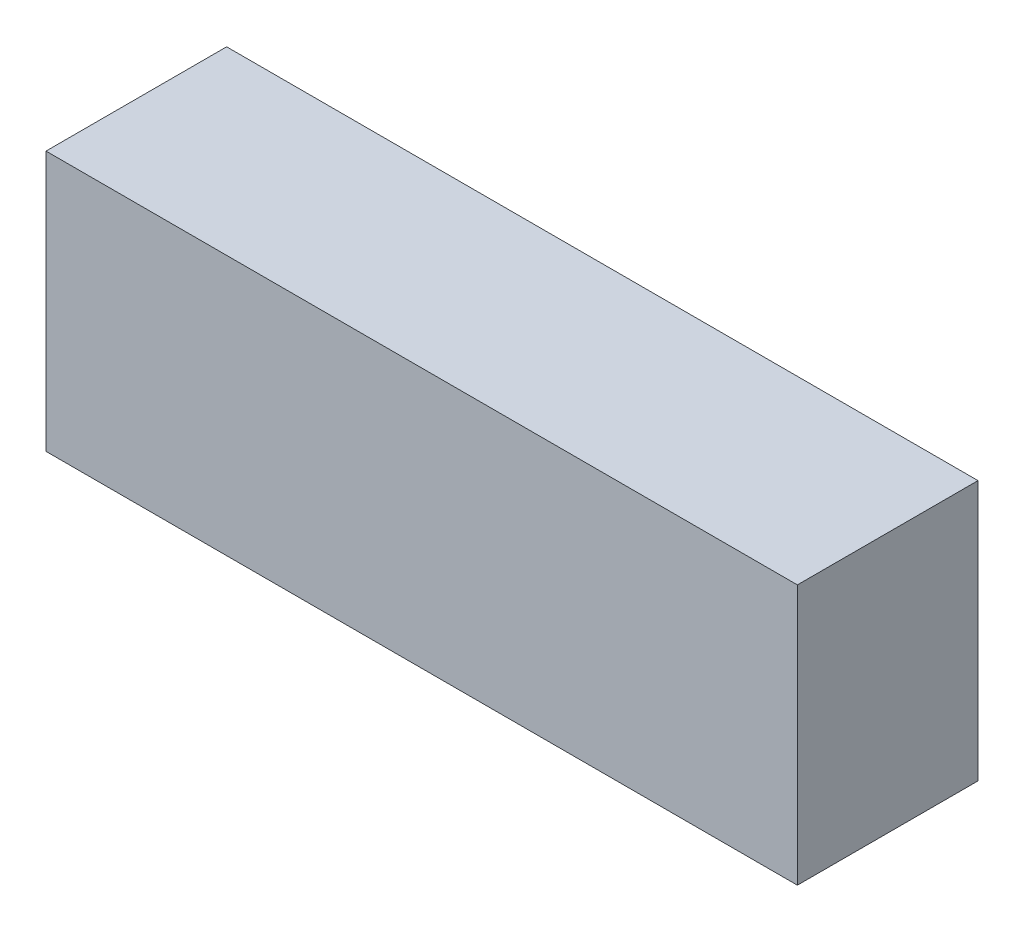
from build123d import *

# Parameters (mm, degrees)
SKETCH1_W           = 104
SKETCH1_H           = 36
BOSS_EXTRUDE1_DEPTH = 25


with BuildPart() as part:
    # Sketch1 → Boss-Extrude1 (new body)
    with BuildSketch(Plane.XY):
        Rectangle(SKETCH1_W, SKETCH1_H)
    extrude(amount=BOSS_EXTRUDE1_DEPTH)


solid = part.part
